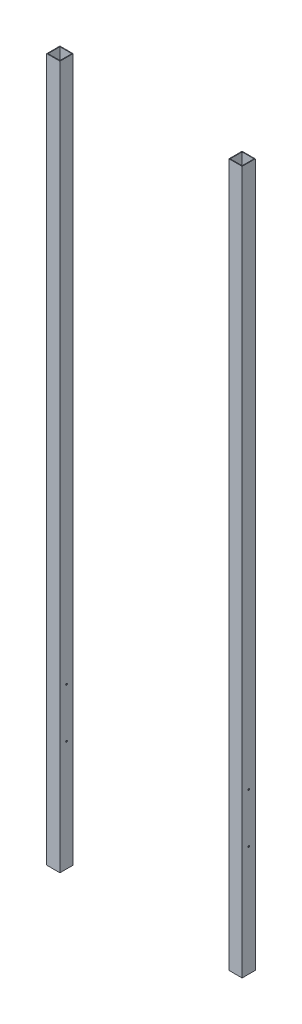
from build123d import *

# Parameters (mm, degrees)
SKETCH1_W                      = 35.56
SKETCH1_H                      = 35.56
SKETCH1_W_2                    = 32.258
SKETCH1_H_2                    = 32.258
BOSS_EXTRUDE1_DEPTH            = 1898.65
BOSS_EXTRUDE1_2_DEPTH          = 1898.65
SKETCH4_W                      = 2.15265
SKETCH4_H                      = 527.685
F_8_CLEARANCE_HOLE1_AT_2_COUNT = 2
F_8_CLEARANCE_HOLE1_AT_2_PITCH = 133.35


with BuildPart() as part:
    # Sketch1 → Boss-Extrude1 (new body)
    with BuildSketch(Plane(origin=(0, 0, 0), x_dir=(1, 0, 0), z_dir=(0, 1, 0))):
        with Locations((16.129, 16.129)):
            Rectangle(SKETCH1_W, SKETCH1_H)
        with Locations((16.129, 16.129)):
            Rectangle(SKETCH1_W_2, SKETCH1_H_2, mode=Mode.SUBTRACT)
    extrude(amount=BOSS_EXTRUDE1_DEPTH)


with BuildPart() as body_2:
    # Sketch1 → Boss-Extrude1 2 (new body)
    with BuildSketch(Plane(origin=(0, 0, 0), x_dir=(1, 0, 0), z_dir=(0, 1, 0))):
        with Locations((508.254, 16.129)):
            Rectangle(SKETCH1_W, SKETCH1_H)
        with Locations((508.254, 16.129)):
            Rectangle(SKETCH1_W_2, SKETCH1_H_2, mode=Mode.SUBTRACT)
    extrude(amount=BOSS_EXTRUDE1_2_DEPTH)


with BuildPart() as f_8_clearance_hole1_tool:
    # Sketch4 → #8 Clearance Hole1 (revolve)
    with BuildSketch(Plane(origin=(526.034, 298.45, -16.129), x_dir=(0, 0, -1), z_dir=(0, 1, 0))):
        with Locations((1.076325, 263.8425)):
            Rectangle(SKETCH4_W, SKETCH4_H)
    f_8_clearance_hole1 = revolve(axis=Axis((532.384, 298.45, -16.129), (-1, 0, 0)))


with BuildPart() as part_1:
    add(part.part)

    # #8 Clearance Hole1: cut by f_8_clearance_hole1_tool
    add(f_8_clearance_hole1_tool.part, mode=Mode.SUBTRACT)


with BuildPart() as body_2_1:
    add(body_2.part)

    # #8 Clearance Hole1: cut by f_8_clearance_hole1_tool
    add(f_8_clearance_hole1_tool.part, mode=Mode.SUBTRACT)


with BuildPart() as f_8_clearance_hole1_at_2_tool:
    # #8 Clearance Hole1 at 2: #8 Clearance Hole1 ×2
    with Locations(*[(0, i * F_8_CLEARANCE_HOLE1_AT_2_PITCH, 0) for i in range(1, F_8_CLEARANCE_HOLE1_AT_2_COUNT)]):
        add(f_8_clearance_hole1)


with BuildPart() as part_2:
    add(part_1.part)

    # #8 Clearance Hole1 at 2: cut by f_8_clearance_hole1_at_2_tool
    add(f_8_clearance_hole1_at_2_tool.part, mode=Mode.SUBTRACT)


with BuildPart() as body_2_2:
    add(body_2_1.part)

    # #8 Clearance Hole1 at 2: cut by f_8_clearance_hole1_at_2_tool
    add(f_8_clearance_hole1_at_2_tool.part, mode=Mode.SUBTRACT)


solid = Compound([part_2.part, body_2_2.part])
